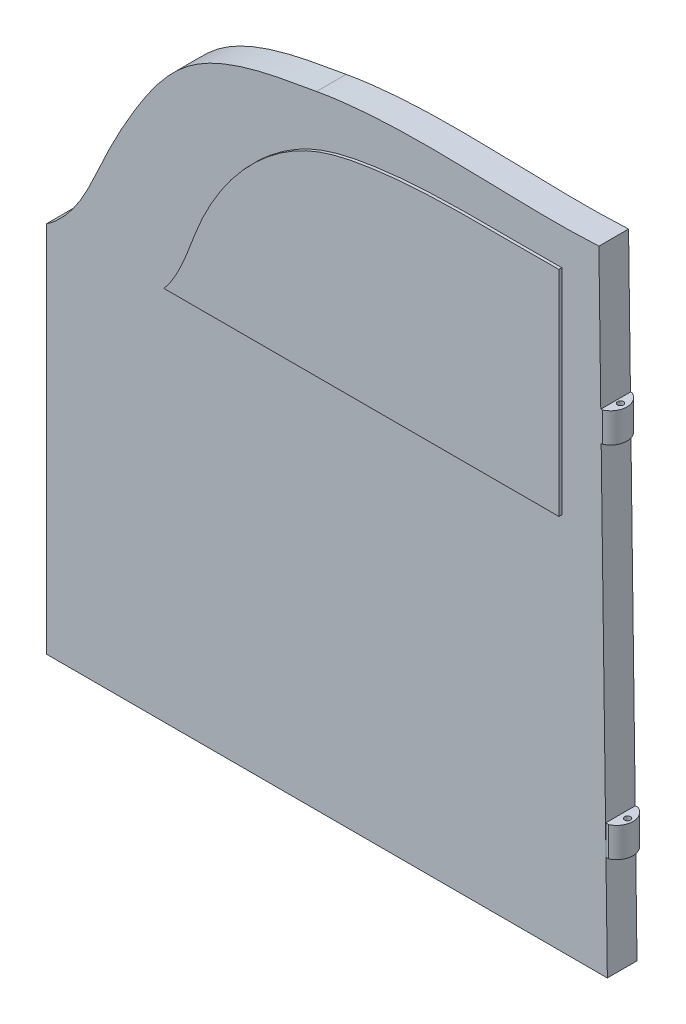
from build123d import *

# Parameters (mm, degrees)
BOSS_EXTRUDE1_DEPTH      = 10
BOSS_EXTRUDE2_DEPTH      = 1
BOSS_EXTRUDE2_DEPTH_BACK = 11
BOSS_EXTRUDE3_DEPTH      = 5
BOSS_EXTRUDE3_DEPTH_BACK = 5
BOSS_EXTRUDE4_DEPTH      = 5
BOSS_EXTRUDE4_DEPTH_BACK = 5
SKETCH19_R               = 1
CUT_EXTRUDE3_DEPTH       = 10
SKETCH24_R               = 1
CUT_EXTRUDE4_DEPTH       = 10
REVOLVE2_ANGLE           = 90
CUT_REVOLVE4_ANGLE       = 80


with BuildPart() as part:
    # Sketch1 → Boss-Extrude1 (new body)
    with BuildSketch(Plane.XY):
        with BuildLine():
            Line((186.280110435, 212.216863761), (189.127439812, 0))
            Line((189.127439812, 0), (0, 0))
            Line((0, 0), (0, 125.576698411))
            add(Edge.make_bspline(
                [(0, 125.576698411), (10.557001905, 132.837635912), (17.098165485, 150.751131911), (30.538510921, 175.76338894), (49.352217031, 203.04075133), (76.867896029, 207.296992896), (91.097956951, 209.776295723)],
                knots=[0, 0, 0, 0, 0.275246051, 0.426571591, 0.655828837, 1, 1, 1, 1], degree=3))
            add(Edge.make_bspline(
                [(91.097956951, 209.776295723), (122.565116695, 215.374757588), (154.60100966, 210.515513687), (186.280110435, 212.216863761)],
                knots=[0, 0, 0, 0, 1, 1, 1, 1], degree=3))
        make_face()
    extrude(amount=BOSS_EXTRUDE1_DEPTH)

    # Sketch3 → Boss-Extrude2 (add, two sides: drawn at the far end of the back side and taken through both)
    with BuildSketch(Plane.XY.offset(10).offset(-BOSS_EXTRUDE2_DEPTH_BACK)):
        with BuildLine():
            Line((40.691917073, 127.565231362), (173.80372619, 127.565231362))
            Line((173.80372619, 127.565231362), (173.80372619, 199.679337801))
            add(Edge.make_bspline(
                [(40.691917073, 127.565231362), (46.771290341, 134.933306827), (53.369134393, 161.704453989), (78.457507643, 191.212262771), (124.31750344, 201.038762955), (152.264868916, 199.362802741), (173.80372619, 199.679337801)],
                knots=[0, 0, 0, 0, 0.16561761, 0.500501685, 0.611599227, 1, 1, 1, 1], degree=3))
        make_face()
    extrude(amount=BOSS_EXTRUDE2_DEPTH + BOSS_EXTRUDE2_DEPTH_BACK)

    # Sketch17 → Boss-Extrude3 (add, two sides: drawn at the far end of the back side and taken through both)
    with BuildSketch(Plane(origin=(0, 40, 0), x_dir=(-1, 0, 0), z_dir=(0, -1, 0)).offset(-BOSS_EXTRUDE3_DEPTH_BACK)):
        with BuildLine():
            Line((-188.57501815, 0), (-189.57501815, 0))
            ThreePointArc((-189.57501815, 0), (-192.762810227, -4.99036016), (-189.57501815, -9.98072032))
            Line((-189.57501815, -9.98072032), (-188.57501815, -9.98072032))
            Line((-188.57501815, -9.98072032), (-188.57501815, 0))
        make_face()
    extrude(amount=BOSS_EXTRUDE3_DEPTH + BOSS_EXTRUDE3_DEPTH_BACK)

    # Sketch18 → Boss-Extrude4 (add, two sides: drawn at the far end of the back side and taken through both)
    with BuildSketch(Plane(origin=(0, 160, 0), x_dir=(-1, 0, 0), z_dir=(0, -1, 0)).offset(-BOSS_EXTRUDE4_DEPTH_BACK)):
        with BuildLine():
            Line((-186.972854644, -10), (-187.472854644, -10))
            ThreePointArc((-187.472854644, -10), (-190.720096746, -5), (-187.472854644, 0))
            Line((-187.472854644, 0), (-186.972854644, 0))
            Line((-186.972854644, 0), (-186.972854644, -10))
        make_face()
    extrude(amount=BOSS_EXTRUDE4_DEPTH + BOSS_EXTRUDE4_DEPTH_BACK)

    # Sketch19 → Cut-Extrude3 (cut)
    with BuildSketch(Plane.XZ.offset(-155)):
        with Locations((188.57501815, 5)):
            Circle(SKETCH19_R)
    extrude(amount=-CUT_EXTRUDE3_DEPTH, mode=Mode.SUBTRACT)

    # Sketch24 → Cut-Extrude4 (cut)
    with BuildSketch(Plane.XZ.offset(-35)):
        with Locations((190.94512502, 4.99518008)):
            Circle(SKETCH24_R)
    extrude(amount=-CUT_EXTRUDE4_DEPTH, mode=Mode.SUBTRACT)

    # Sketch30 → Revolve2 (revolve)
    with BuildSketch(Plane(origin=(0, 100, 0), x_dir=(1, 0, 0), z_dir=(0, 1, 0))):
        with BuildLine():
            Line((17.967687334, 0), (42.032312666, 0))
            ThreePointArc((42.032312666, 0), (30, 12.032312666), (17.967687334, 0))
        make_face()
    revolve(axis=Axis((17.967687334, 100, 0), (1, 0, 0)), revolution_arc=REVOLVE2_ANGLE)

    # Sketch31 → Cut-Revolve4 (revolve, cut)
    with BuildSketch(Plane.XZ.offset(-100)):
        with BuildLine():
            Line((20.003479707, 0), (39.804560833, 0))
            ThreePointArc((39.804560833, 0), (29.90402027, -9.900540563), (20.003479707, 0))
        make_face()
    revolve(axis=Axis((20.003479707, 100, 0), (1, 0, 0)), revolution_arc=CUT_REVOLVE4_ANGLE, mode=Mode.SUBTRACT)


solid = part.part
